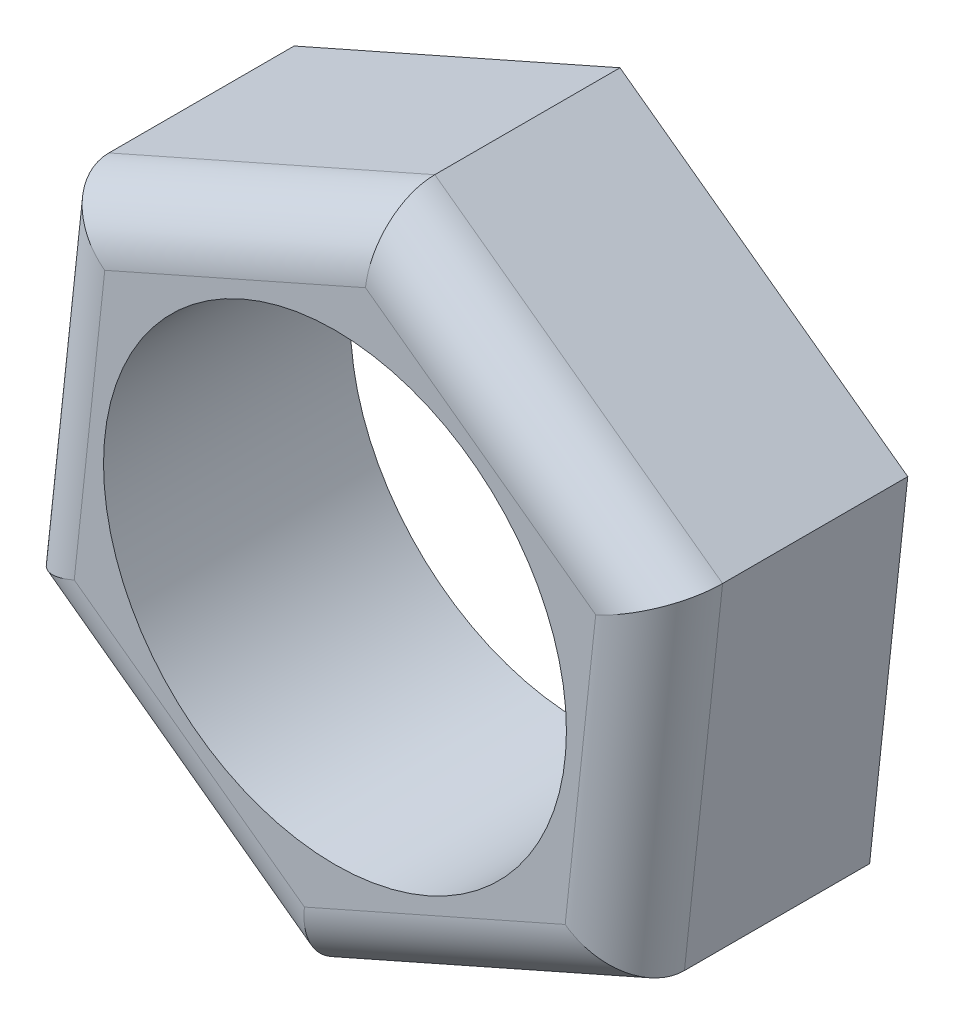
from build123d import *

# Parameters (mm, degrees)
SKETCH1_R           = 4.7625
BOSS_EXTRUDE1_DEPTH = 5.08
FILLET1_R           = 1.27


with BuildPart() as part:
    # Sketch1 → Boss-Extrude1 (new body)
    with BuildSketch(Plane.XY):
        Polygon((6.705982891, 2.965320691), (0.784948396, 7.290211886), (-5.921034494, 4.324891195), (-6.705982891, -2.965320691), (-0.784948396, -7.290211886), (5.921034494, -4.324891195), align=None)
        Circle(SKETCH1_R, mode=Mode.SUBTRACT)
    extrude(amount=BOSS_EXTRUDE1_DEPTH)

    # Fillet1
    fillet1_edges = [part.edges().sort_by_distance(p)[0] for p in [
        (-3.745465644, -5.127766289, 5.08),
        (2.568043049, -5.807551541, 5.08),
        (6.313508693, -0.679785252, 5.08),
        (3.745465644, 5.127766289, 5.08),
        (-6.313508693, 0.679785252, 5.08),
        (-2.568043049, 5.807551541, 5.08),
    ]]
    fillet(fillet1_edges, radius=FILLET1_R)


solid = part.part
